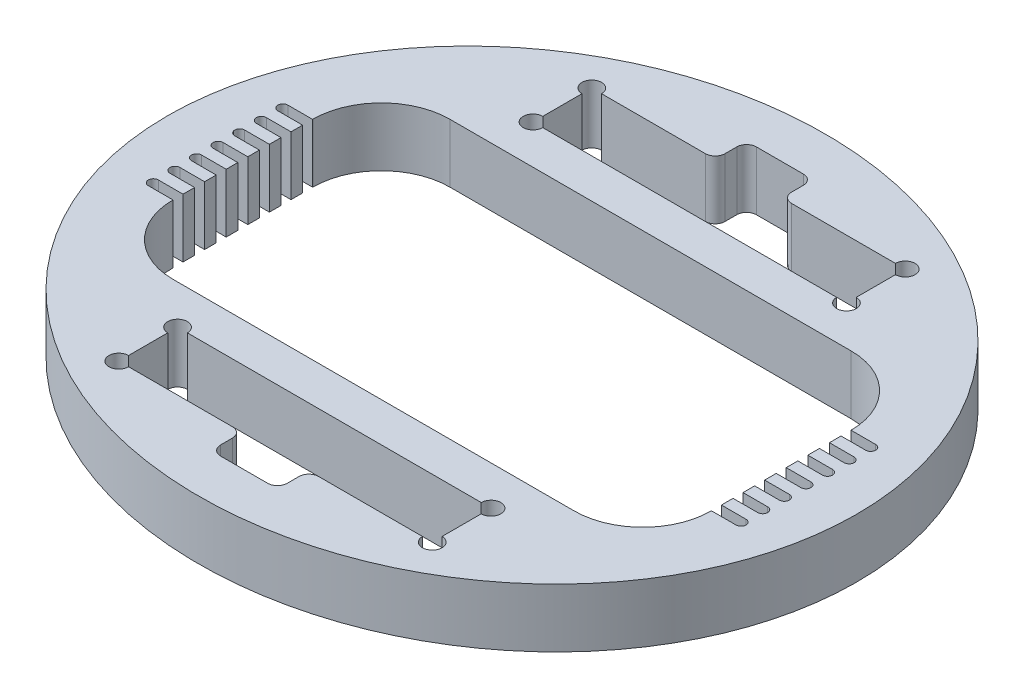
from build123d import *

# Parameters (mm, degrees)
SKETCH11_RX                  = 55.88
SKETCH11_RY                  = 50.8
BOSS_EXTRUDE4_DEPTH          = 9.525
SKETCH14_R                   = 0.0001
CUT_EXTRUDE5_DEPTH           = 77.117934976
CUT_EXTRUDE4_DEPTH           = 77.117934976
LPATTERN1_COUNT              = 4
LPATTERN1_PITCH              = 3.5
LPATTERN1_COL_COUNT          = 4
LPATTERN1_COL_PITCH          = 3.5
MIRROR1_COPY_1_DEPTH         = 77.117934976
MIRROR1_COPY_2_DEPTH         = 77.117934976
MIRROR1_COPY_3_DEPTH         = 77.117934976
MIRROR1_COPY_4_DEPTH         = 77.117934976
MIRROR1_COPY_5_DEPTH         = 77.117934976
MIRROR1_COPY_6_DEPTH         = 77.117934976
MIRROR1_COPY_7_DEPTH         = 77.117934976
F_1_8_0_125_DIAMETER_HOLE1_D = 3.175


with BuildPart() as part:
    # Sketch11 → Boss-Extrude4 (new body)
    with BuildSketch(Plane(origin=(0, 0, 0), x_dir=(1, 0, 0), z_dir=(0, 1, 0))):
        with Locations(Location((0, 0), (0, 0, 180))):
            Ellipse(SKETCH11_RX, SKETCH11_RY)
        with BuildLine():
            Line((-32.5125, 22.448135593), (32.5125, 22.448135593))
            ThreePointArc((32.5125, 22.448135593), (40.370224106, 19.193359699), (43.625, 11.335635593))
            Line((43.625, 11.335635593), (43.625, -11.335635593))
            ThreePointArc((43.625, -11.335635593), (40.370224106, -19.193359699), (32.5125, -22.448135593))
            Line((32.5125, -22.448135593), (-32.5125, -22.448135593))
            ThreePointArc((-32.5125, -22.448135593), (-40.370224106, -19.193359699), (-43.625, -11.335635593))
            Line((-43.625, -11.335635593), (-43.625, 11.335635593))
            ThreePointArc((-43.625, 11.335635593), (-40.370224106, 19.193359699), (-32.5125, 22.448135593))
        make_face(mode=Mode.SUBTRACT)
    extrude(amount=BOSS_EXTRUDE4_DEPTH)

    # Sketch14 → Cut-Extrude5 (cut, through all)
    with BuildSketch(Plane(origin=(0, 9.525, 0), x_dir=(1, 0, 0), z_dir=(0, 1, 0))):
        with Locations((-25.4, 28.798235593)):
            Circle(SKETCH14_R)
        with Locations((25.4, 28.798235593)):
            Circle(SKETCH14_R)
        with Locations((25.4, 38.323035593)):
            Circle(SKETCH14_R)
        with Locations((-25.4, 38.323035593)):
            Circle(SKETCH14_R)
        with BuildLine():
            Line((-25.4, 38.323135593), (-6.981368472, 38.323135593))
            ThreePointArc((-6.981368472, 38.323135593), (-5.858836457, 38.788103578), (-5.393868472, 39.910635593))
            Line((-5.393868472, 39.910635593), (-5.393868472, 41.815635593))
            ThreePointArc((-5.393868472, 41.815635593), (-4.928900487, 42.938167608), (-3.806368472, 43.403135593))
            Line((-3.806368472, 43.403135593), (3.806368472, 43.403135593))
            ThreePointArc((3.806368472, 43.403135593), (4.928900487, 42.938167608), (5.393868472, 41.815635593))
            Line((5.393868472, 41.815635593), (5.393868472, 39.910635593))
            ThreePointArc((5.393868472, 39.910635593), (5.858836457, 38.788103578), (6.981368472, 38.323135593))
            Line((6.981368472, 38.323135593), (25.4001, 38.323035593))
            Line((25.4001, 38.323035593), (25.4, 28.798135593))
            Line((25.4, 28.798135593), (-25.4001, 28.798235593))
            Line((-25.4001, 28.798235593), (-25.4, 38.323135593))
        make_face()
    cut_extrude5 = extrude(amount=-CUT_EXTRUDE5_DEPTH, mode=Mode.SUBTRACT)

    # Sketch12 → Cut-Extrude4 (cut, through all)
    with BuildSketch(Plane(origin=(0, 9.525, 0), x_dir=(1, 0, 0), z_dir=(0, 1, 0))):
        with BuildLine():
            Line((-43.625, 0.81), (-47.625, 0.81))
            ThreePointArc((-47.625, 0.81), (-48.435, 0), (-47.625, -0.81))
            Line((-47.625, -0.81), (-43.625, -0.81))
            Line((-43.625, -0.81), (-43.625, 0.81))
        make_face()
    cut_extrude4 = extrude(amount=-CUT_EXTRUDE4_DEPTH, mode=Mode.SUBTRACT)

    # LPattern1: Cut-Extrude4 ×4
    with Locations(*[(0, 0, -i * LPATTERN1_PITCH) for i in range(1, LPATTERN1_COUNT)]):
        add(cut_extrude4, mode=Mode.SUBTRACT)

    # LPattern1 col: Cut-Extrude4 ×4
    with Locations(*[(0, 0, i * LPATTERN1_COL_PITCH) for i in range(1, LPATTERN1_COL_COUNT)]):
        add(cut_extrude4, mode=Mode.SUBTRACT)

    # Mirror1 copy 1 sketch → Mirror1 copy 1 (cut, through all)
    with BuildSketch(Plane(origin=(0, 9.525, -3.5), x_dir=(-1, 0, 0), z_dir=(0, 1, 0))):
        with BuildLine():
            Line((-43.625, -0.81), (-47.625, -0.81))
            ThreePointArc((-47.625, -0.81), (-48.435, 0), (-47.625, 0.81))
            Line((-47.625, 0.81), (-43.625, 0.81))
            Line((-43.625, 0.81), (-43.625, -0.81))
        make_face()
    extrude(amount=-MIRROR1_COPY_1_DEPTH, mode=Mode.SUBTRACT)

    # Mirror1 copy 2 sketch → Mirror1 copy 2 (cut, through all)
    with BuildSketch(Plane(origin=(0, 9.525, -7), x_dir=(-1, 0, 0), z_dir=(0, 1, 0))):
        with BuildLine():
            Line((-43.625, -0.81), (-47.625, -0.81))
            ThreePointArc((-47.625, -0.81), (-48.435, 0), (-47.625, 0.81))
            Line((-47.625, 0.81), (-43.625, 0.81))
            Line((-43.625, 0.81), (-43.625, -0.81))
        make_face()
    extrude(amount=-MIRROR1_COPY_2_DEPTH, mode=Mode.SUBTRACT)

    # Mirror1 copy 3 sketch → Mirror1 copy 3 (cut, through all)
    with BuildSketch(Plane(origin=(0, 9.525, -10.5), x_dir=(-1, 0, 0), z_dir=(0, 1, 0))):
        with BuildLine():
            Line((-43.625, -0.81), (-47.625, -0.81))
            ThreePointArc((-47.625, -0.81), (-48.435, 0), (-47.625, 0.81))
            Line((-47.625, 0.81), (-43.625, 0.81))
            Line((-43.625, 0.81), (-43.625, -0.81))
        make_face()
    extrude(amount=-MIRROR1_COPY_3_DEPTH, mode=Mode.SUBTRACT)

    # Mirror1 copy 4 sketch → Mirror1 copy 4 (cut, through all)
    with BuildSketch(Plane(origin=(0, 9.525, 3.5), x_dir=(-1, 0, 0), z_dir=(0, 1, 0))):
        with BuildLine():
            Line((-43.625, -0.81), (-47.625, -0.81))
            ThreePointArc((-47.625, -0.81), (-48.435, 0), (-47.625, 0.81))
            Line((-47.625, 0.81), (-43.625, 0.81))
            Line((-43.625, 0.81), (-43.625, -0.81))
        make_face()
    extrude(amount=-MIRROR1_COPY_4_DEPTH, mode=Mode.SUBTRACT)

    # Mirror1 copy 5 sketch → Mirror1 copy 5 (cut, through all)
    with BuildSketch(Plane(origin=(0, 9.525, 7), x_dir=(-1, 0, 0), z_dir=(0, 1, 0))):
        with BuildLine():
            Line((-43.625, -0.81), (-47.625, -0.81))
            ThreePointArc((-47.625, -0.81), (-48.435, 0), (-47.625, 0.81))
            Line((-47.625, 0.81), (-43.625, 0.81))
            Line((-43.625, 0.81), (-43.625, -0.81))
        make_face()
    extrude(amount=-MIRROR1_COPY_5_DEPTH, mode=Mode.SUBTRACT)

    # Mirror1 copy 6 sketch → Mirror1 copy 6 (cut, through all)
    with BuildSketch(Plane(origin=(0, 9.525, 10.5), x_dir=(-1, 0, 0), z_dir=(0, 1, 0))):
        with BuildLine():
            Line((-43.625, -0.81), (-47.625, -0.81))
            ThreePointArc((-47.625, -0.81), (-48.435, 0), (-47.625, 0.81))
            Line((-47.625, 0.81), (-43.625, 0.81))
            Line((-43.625, 0.81), (-43.625, -0.81))
        make_face()
    extrude(amount=-MIRROR1_COPY_6_DEPTH, mode=Mode.SUBTRACT)

    # Mirror1 copy 7 sketch → Mirror1 copy 7 (cut, through all)
    with BuildSketch(Plane(origin=(0, 9.525, 0), x_dir=(-1, 0, 0), z_dir=(0, 1, 0))):
        with BuildLine():
            Line((-43.625, -0.81), (-47.625, -0.81))
            ThreePointArc((-47.625, -0.81), (-48.435, 0), (-47.625, 0.81))
            Line((-47.625, 0.81), (-43.625, 0.81))
            Line((-43.625, 0.81), (-43.625, -0.81))
        make_face()
    extrude(amount=-MIRROR1_COPY_7_DEPTH, mode=Mode.SUBTRACT)

    # Mirror2: Cut-Extrude5 across plane
    add(cut_extrude5.mirror(Plane.XY), mode=Mode.SUBTRACT)

    # 1_8 _0.125_ Diameter Hole1 (through all)
    with Locations(Plane(origin=(0, 9.525, 0), x_dir=(1, 0, 0), z_dir=(0, 1, 0))):
        with Locations((-25.4001, 28.798235593), (-25.4001, 38.323035593), (25.4001, 38.323035593), (25.4, 28.798135593), (-25.4, -28.798135593), (-25.4001, -38.323035593), (25.4, -28.798135593), (25.4001, -38.323035593)):
            Hole(F_1_8_0_125_DIAMETER_HOLE1_D / 2)


solid = part.part
